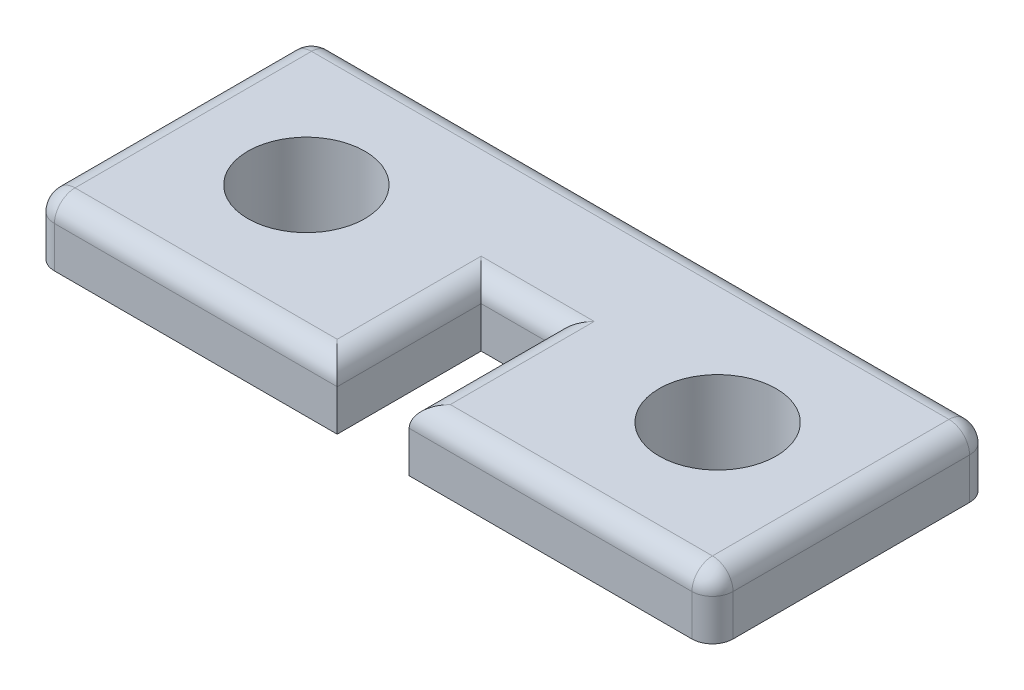
from build123d import *

# Parameters (mm, degrees)
SKETCH1_R           = 1.4225
BOSS_EXTRUDE1_DEPTH = 1.5
SKETCH2_R           = 2.0225
SKETCH2_R_2         = 1.4225
BOSS_EXTRUDE2_DEPTH = 1.5
FILLET1_R           = 0.5
FILLET2_R           = 0.5


with BuildPart() as part:
    # Sketch1 → Boss-Extrude1 (new body)
    with BuildSketch(Plane(origin=(0, 0, 0), x_dir=(1, 0, 0), z_dir=(0, 1, 0))):
        Polygon((-8.25, -3.375), (-8.25, 3.375), (8.25, 3.375), (8.25, -3.375), (0.875, -3.375), (0.875, 0.125), (-0.875, 0.125), (-0.875, -3.375), align=None)
        with Locations((-5, 0)):
            Circle(SKETCH1_R, mode=Mode.SUBTRACT)
        with Locations((5, 0)):
            Circle(SKETCH1_R, mode=Mode.SUBTRACT)
    extrude(amount=BOSS_EXTRUDE1_DEPTH)

    # Sketch2 → Boss-Extrude2 (add)
    with BuildSketch(Plane.XZ):
        with Locations((5, 0)):
            Circle(SKETCH2_R)
        with Locations((5, 0)):
            Circle(SKETCH2_R_2, mode=Mode.SUBTRACT)
        with Locations((-5, 0)):
            Circle(SKETCH2_R)
        with Locations((-5, 0)):
            Circle(SKETCH2_R_2, mode=Mode.SUBTRACT)
    extrude(amount=BOSS_EXTRUDE2_DEPTH)

    # Fillet1
    fillet1_edges = [part.edges().sort_by_distance(p)[0] for p in [
        (2.9775, -1.5, 0),
        (-7.0225, -1.5, 0),
    ]]
    fillet(fillet1_edges, radius=FILLET1_R)

    # Fillet2
    fillet2_edges = [part.edges().sort_by_distance(p)[0] for p in [
        (-8.25, 1.5, 0),
        (-4.5625, 1.5, 3.375),
        (8.25, 0.75, 3.375),
        (-8.25, 0.75, 3.375),
        (-8.25, 0.75, -3.375),
        (8.25, 0.75, -3.375),
        (-0.875, 1.5, 1.625),
        (0, 1.5, -0.125),
        (0.875, 1.5, 1.625),
        (4.5625, 1.5, 3.375),
        (8.25, 1.5, 0),
        (0, 1.5, -3.375),
    ]]
    fillet(fillet2_edges, radius=FILLET2_R)


solid = part.part
